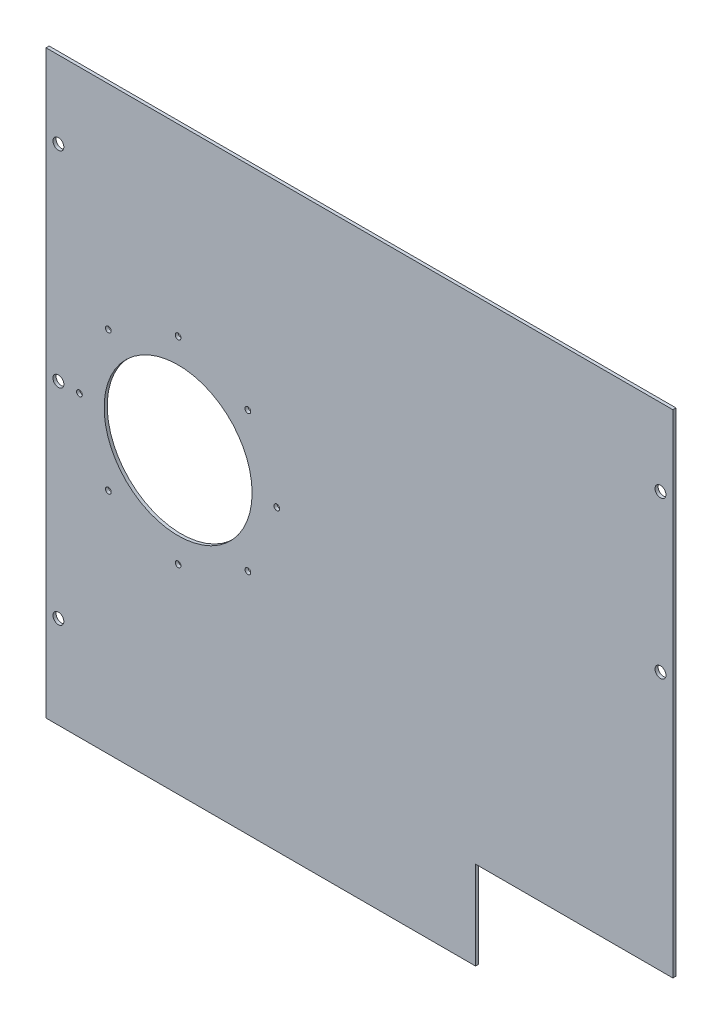
from build123d import *

# Parameters (mm, degrees)
BOSS_EXTRUDE1_DEPTH        = 1.6002
SKETCH2_R                  = 38.1
CUT_EXTRUDE1_DEPTH         = 2.6002
CIRPATTERN1_COUNT          = 8
F_10_CLEARANCE_HOLE1_D     = 5.6134
F_10_CLEARANCE_HOLE1_DEPTH = 9.53
F_10_CLEARANCE_HOLE1_TIP   = 1.686435499


with BuildPart() as part:
    # Sketch1 → Boss-Extrude1 (new body)
    with BuildSketch(Plane.XY):
        Polygon((161.3627, -107.93570835), (59.7625, -107.93570835), (59.7625, -153.41070835), (-161.3627, -153.41070835), (-161.3627, 145.48590835), (161.3627, 145.48590835), align=None)
    extrude(amount=BOSS_EXTRUDE1_DEPTH)

    # Sketch2 → Cut-Extrude1 (cut, through all)
    with BuildSketch(Plane.XY.offset(1.6002)):
        with Locations((-93.3627, 0)):
            Circle(SKETCH2_R)
    extrude(amount=-CUT_EXTRUDE1_DEPTH, mode=Mode.SUBTRACT)

    # Sketch11 → #4 Clearance Hole1 (revolve, cut)
    with BuildSketch(Plane(origin=(-93.3627, 50.8, 1.6002), x_dir=(0, -1, 0), z_dir=(1, 0, 0))):
        Polygon((0, 0), (0, 173.855187864), (1.4732, 172.97), (1.4732, 0), align=None)
    f_4_clearance_hole1 = revolve(axis=Axis((-93.3627, 50.8, 7.9502), (0, 0, -1)), mode=Mode.SUBTRACT)

    # CirPattern1: #4 Clearance Hole1 ×8 about axis
    cirpattern1_axis = Axis((-93.3627, 0, 0), (0, 0, 1))
    for i in range(1, CIRPATTERN1_COUNT):
        add(f_4_clearance_hole1.rotate(cirpattern1_axis, i * 360 / CIRPATTERN1_COUNT), mode=Mode.SUBTRACT)

    # #10 Clearance Hole1
    with Locations(Plane.XY.offset(1.6002)):
        with Locations((-155, 105.78570835), (-155, 0), (-155, -105.78570835), (155, 105.78570835), (155, 25.27849165)):
            Hole(F_10_CLEARANCE_HOLE1_D / 2, depth=F_10_CLEARANCE_HOLE1_DEPTH)
            with Locations((0, 0, -(F_10_CLEARANCE_HOLE1_DEPTH + F_10_CLEARANCE_HOLE1_TIP / 2))):  # 118° drill point
                Cone(0, F_10_CLEARANCE_HOLE1_D / 2, F_10_CLEARANCE_HOLE1_TIP, mode=Mode.SUBTRACT)


solid = part.part
